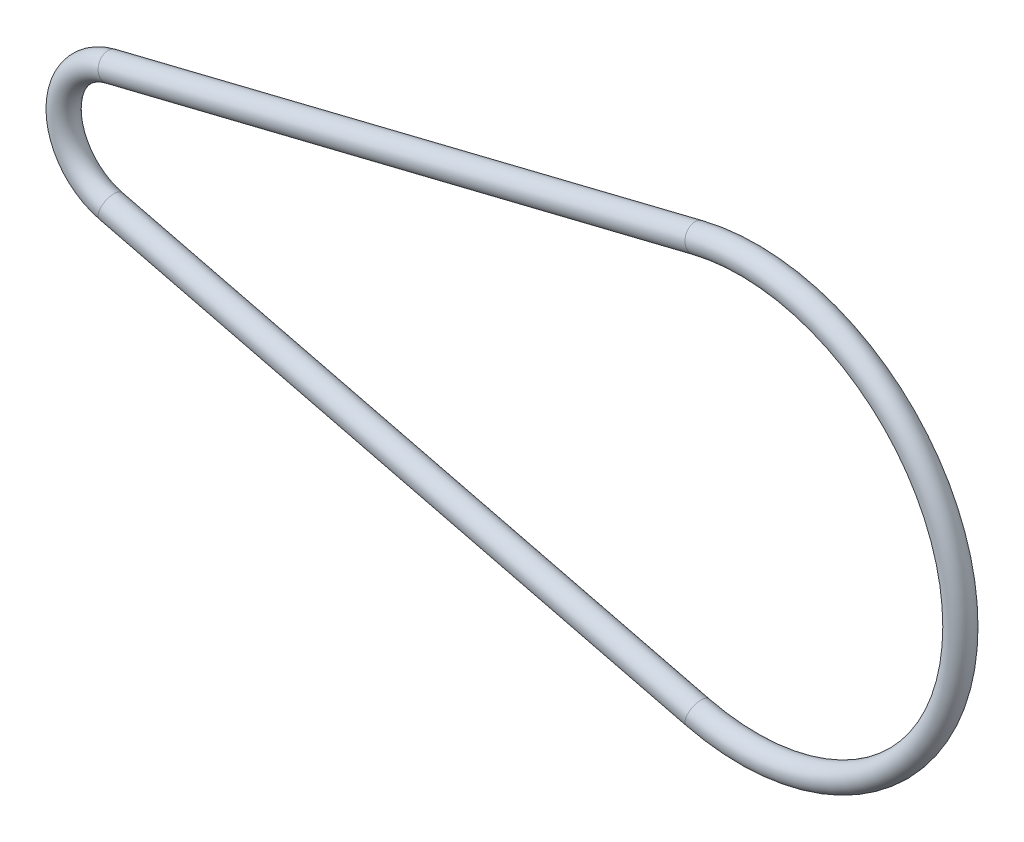
from build123d import *

# Parameters (mm, degrees)
SWEEP1_PROFILE_R = 1


with BuildPart() as part:
    # Sweep1: sweep along a path in Sketch1
    with BuildLine(Plane.XY) as sweep1_path:
        Line((-1.2, 4.85386444), (45.92, 16.503139095))
        ThreePointArc((45.92, 16.503139095), (67, 0), (45.92, -16.503139095))
        Line((45.92, -16.503139095), (-1.2, -4.85386444))
        ThreePointArc((-1.2, -4.85386444), (-5, 0), (-1.2, 4.85386444))
    # Sweep1 profile (on start of the path) → Sweep1 (sweep)
    with BuildSketch(Plane(origin=(-1.2, 4.85386444, 0), x_dir=(-0.24, 0.970772888, 0), z_dir=(0.970772888, 0.24, 0))):
        Circle(SWEEP1_PROFILE_R)
    sweep(path=sweep1_path.line)


solid = part.part
